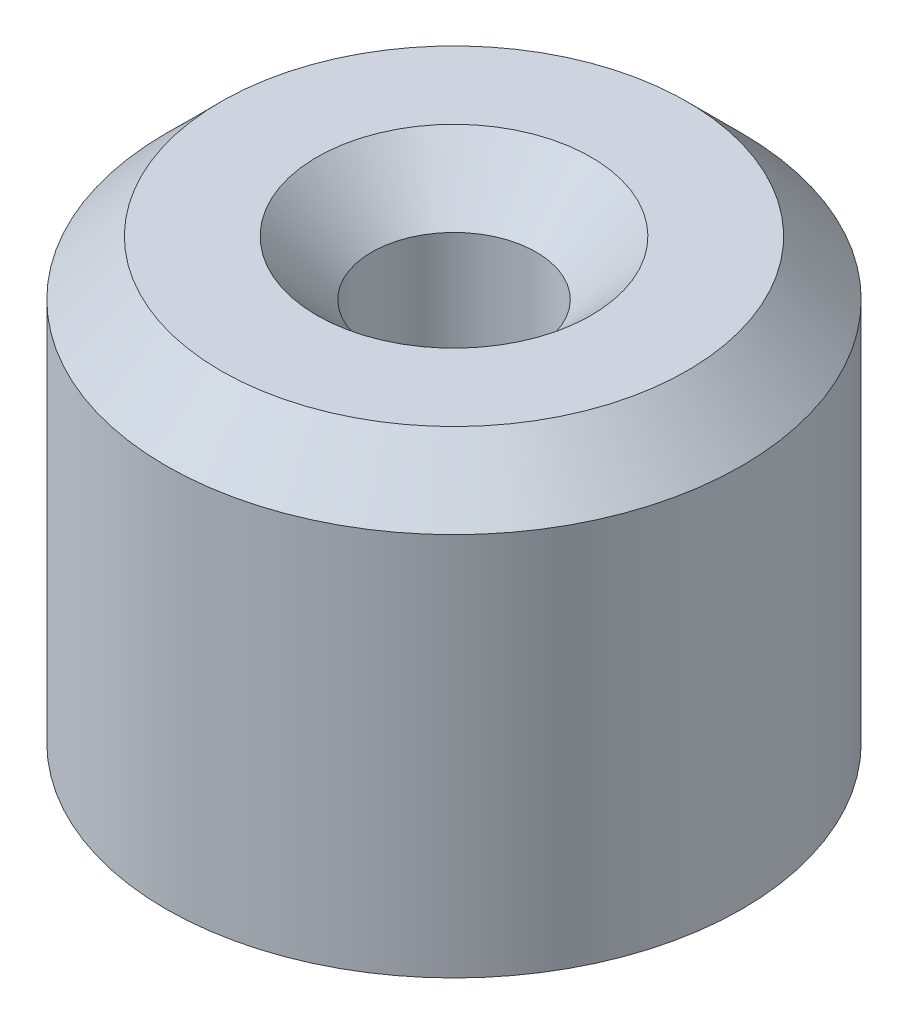
from build123d import *

# Parameters (mm, degrees)
SKETCH1_R           = 5.25
BOSS_EXTRUDE1_DEPTH = 8
SKETCH2_R           = 1.5
CUT_EXTRUDE1_DEPTH  = 6
SHELL1_T            = -1.1
SKETCH3_R           = 1.5
CUT_EXTRUDE2_DEPTH  = 10.545941546
CHAMFER1_SIZE       = 1
CHAMFER2_SIZE       = 1


with BuildPart() as part:
    # Sketch1 → Boss-Extrude1 (new body)
    with BuildSketch(Plane(origin=(0, 0, 0), x_dir=(1, 0, 0), z_dir=(0, 1, 0))):
        with Locations(Location((0, 0, 0), (0, 0, 270))):
            Circle(SKETCH1_R)
    extrude(amount=BOSS_EXTRUDE1_DEPTH)

    # Sketch2 → Cut-Extrude1 (cut)
    with BuildSketch(Plane(origin=(0, 8, 0), x_dir=(1, 0, 0), z_dir=(0, 1, 0))):
        with Locations(Location((0, 0, 0), (0, 0, 270))):
            Circle(SKETCH2_R)
    extrude(amount=-CUT_EXTRUDE1_DEPTH, mode=Mode.SUBTRACT)

    # Shell1
    shell1_openings = [part.faces().sort_by_distance(p)[0] for p in [
        (0, 0, 0),
    ]]
    offset(amount=SHELL1_T, openings=shell1_openings, kind=Kind.INTERSECTION)

    # Sketch3 → Cut-Extrude2 (cut, through all)
    with BuildSketch(Plane(origin=(0, 2, 0), x_dir=(1, 0, 0), z_dir=(0, 1, 0))):
        with Locations(Location((0, 0, 0), (0, 0, 270))):
            Circle(SKETCH3_R)
    extrude(amount=-CUT_EXTRUDE2_DEPTH, mode=Mode.SUBTRACT)

    # Chamfer1
    chamfer1_edges = [part.edges().sort_by_distance(p)[0] for p in [
        (0, 8, -5.25),
    ]]
    chamfer(chamfer1_edges, length=CHAMFER1_SIZE)

    # Chamfer2
    chamfer2_edges = [part.edges().sort_by_distance(p)[0] for p in [
        (0, 8, -1.5),
    ]]
    chamfer(chamfer2_edges, length=CHAMFER2_SIZE)


solid = part.part
